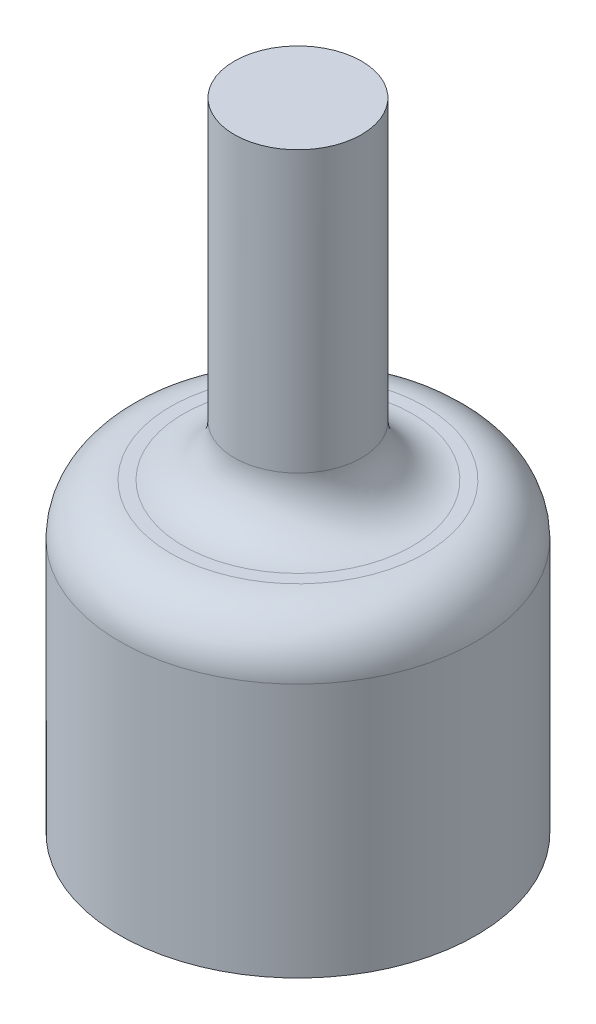
from build123d import *

# Parameters (mm, degrees)
SKETCH1_R           = 12.5
SKETCH1_R_2         = 2
BOSS_EXTRUDE1_DEPTH = 5
SKETCH2_R           = 2.5
BOSS_EXTRUDE2_DEPTH = 15
SKETCH3_R           = 5
CUT_EXTRUDE1_DEPTH  = 2
SKETCH4_R           = 12.5
CUT_EXTRUDE2_DEPTH  = 24.184046239
SKETCH5_R           = 7
BOSS_EXTRUDE3_DEPTH = 10
BOSS_EXTRUDE4_START = -2
SKETCH5_3_R         = 7
BOSS_EXTRUDE4_DEPTH = 2
FILLET1_R           = 2
FILLET2_R           = 2


with BuildPart() as part:
    # Sketch1 → Boss-Extrude1 (new body)
    with BuildSketch(Plane(origin=(0, 0, 0), x_dir=(1, 0, 0), z_dir=(0, 1, 0))):
        Circle(SKETCH1_R)
        with Locations((-7.5, 0)):
            Circle(SKETCH1_R_2, mode=Mode.SUBTRACT)
        with BuildLine():
            ThreePointArc((2, -7.5), (-1.414213562, -8.914213562), (0, -5.5))
            ThreePointArc((0, -5.5), (1.414213562, -6.085786438), (2, -7.5))
        make_face(mode=Mode.SUBTRACT)
        with BuildLine():
            ThreePointArc((9.5, 0), (7.5, -2), (5.5, 0))
            ThreePointArc((5.5, 0), (7.5, 2), (9.5, 0))
        make_face(mode=Mode.SUBTRACT)
        with BuildLine():
            ThreePointArc((2, 7.5), (1.414213562, 6.085786438), (0, 5.5))
            ThreePointArc((0, 5.5), (-1.414213562, 8.914213562), (2, 7.5))
        make_face(mode=Mode.SUBTRACT)
    extrude(amount=BOSS_EXTRUDE1_DEPTH)

    # Sketch2 → Boss-Extrude2 (add)
    with BuildSketch(Plane(origin=(0, 5, 0), x_dir=(1, 0, 0), z_dir=(0, 1, 0))):
        Circle(SKETCH2_R)
    extrude(amount=BOSS_EXTRUDE2_DEPTH)

    # Sketch3 → Cut-Extrude1 (cut)
    with BuildSketch(Plane.XZ):
        Circle(SKETCH3_R)
    extrude(amount=-CUT_EXTRUDE1_DEPTH, mode=Mode.SUBTRACT)

    # Sketch4 → Cut-Extrude2 (cut, through all)
    with BuildSketch(Plane(origin=(0, 5, 0), x_dir=(1, 0, 0), z_dir=(0, 1, 0))):
        Circle(SKETCH4_R)
    extrude(amount=-CUT_EXTRUDE2_DEPTH, mode=Mode.SUBTRACT)

    # Sketch5 → Boss-Extrude3 (add)
    with BuildSketch(Plane.XZ.offset(-5)):
        Circle(SKETCH5_R)
        with BuildLine():
            ThreePointArc((2.374868417, 1.75), (0, -2.95), (-2.374868417, 1.75))
            Line((-2.374868417, 1.75), (2.374868417, 1.75))
        make_face(mode=Mode.SUBTRACT)
    extrude(amount=BOSS_EXTRUDE3_DEPTH)

    # Sketch5_3 → Boss-Extrude4 (add)
    with BuildSketch(Plane.XZ.offset(-5).offset(BOSS_EXTRUDE4_START)):
        Circle(SKETCH5_3_R)
    extrude(amount=BOSS_EXTRUDE4_DEPTH)

    # Fillet1
    fillet1_edges = [part.edges().sort_by_distance(p)[0] for p in [
        (-2.5, 7, 0),
    ]]
    fillet(fillet1_edges, radius=FILLET1_R)

    # Fillet2
    fillet2_edges = [part.edges().sort_by_distance(p)[0] for p in [
        (-7, 7, 0),
    ]]
    fillet(fillet2_edges, radius=FILLET2_R)


solid = part.part
